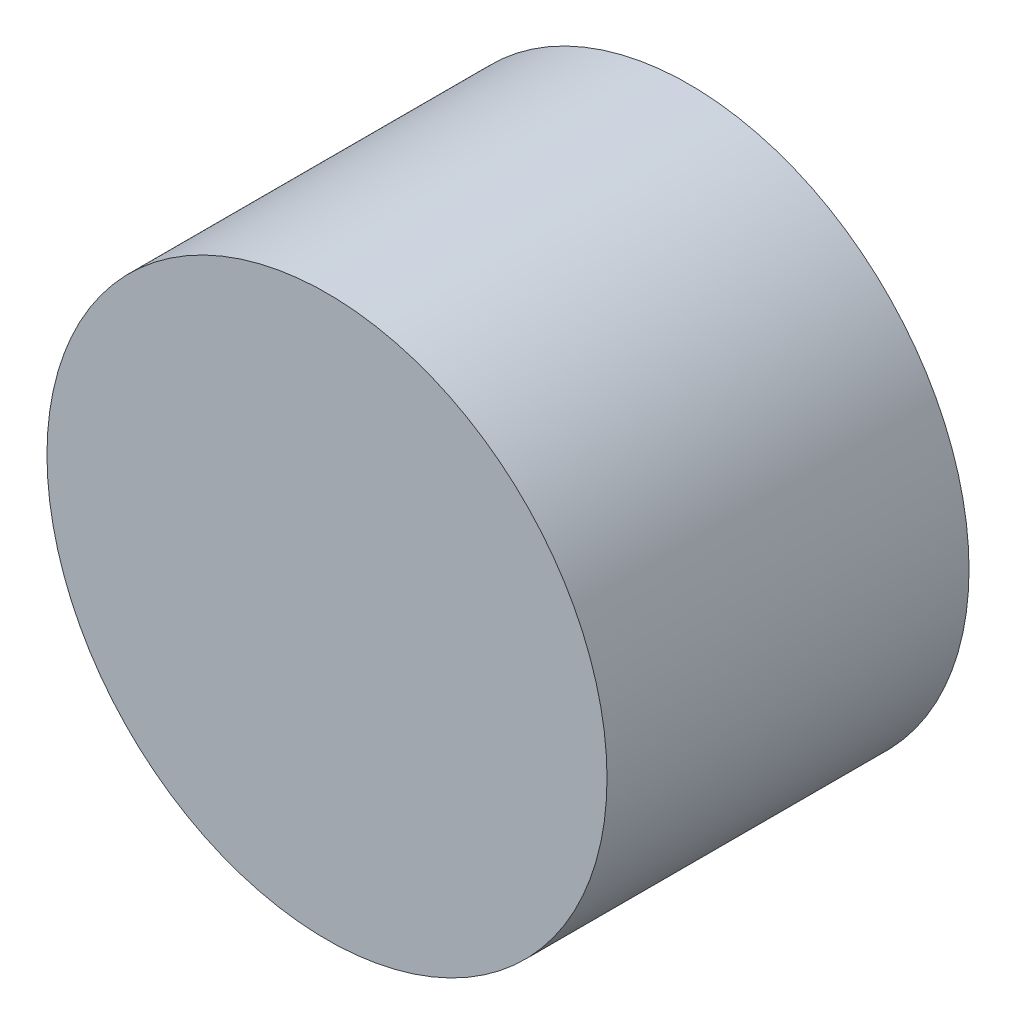
from build123d import *

# Parameters (mm, degrees)
SKETCH1_R           = 8.509
BOSS_EXTRUDE1_DEPTH = 11


with BuildPart() as part:
    # Sketch1 → Boss-Extrude1 (new body)
    with BuildSketch(Plane.XY):
        Circle(SKETCH1_R)
    extrude(amount=BOSS_EXTRUDE1_DEPTH)


solid = part.part
